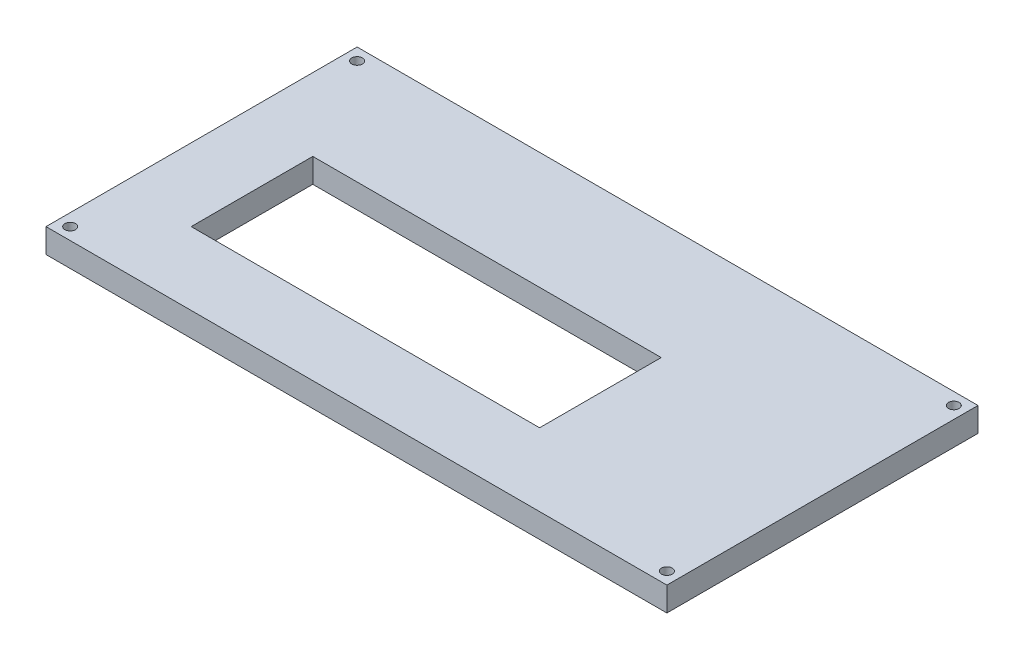
from build123d import *

# Parameters (mm, degrees)
SKETCH1_W           = 128.3
SKETCH1_H           = 64.29
BOSS_EXTRUDE1_DEPTH = 5
SKETCH2_R           = 1.1
CUT_EXTRUDE1_DEPTH  = 6
SKETCH3_W           = 72
SKETCH3_H           = 25.13
CUT_EXTRUDE2_DEPTH  = 6


with BuildPart() as part:
    # Sketch1 → Boss-Extrude1 (new body)
    with BuildSketch(Plane(origin=(0, 0, 0), x_dir=(1, 0, 0), z_dir=(0, 1, 0))):
        with Locations((-64.15, 32.145)):
            Rectangle(SKETCH1_W, SKETCH1_H)
    extrude(amount=BOSS_EXTRUDE1_DEPTH)

    # Sketch2 → Cut-Extrude1 (cut, through all)
    with BuildSketch(Plane(origin=(0, 0, 0), x_dir=(-1, 0, 0), z_dir=(0, -1, 0))):
        with Locations((125.8, 2.5)):
            Circle(SKETCH2_R)
        with Locations((125.8, 61.79)):
            Circle(SKETCH2_R)
        with Locations((2.5, 2.5)):
            Circle(SKETCH2_R)
        with Locations((2.5, 61.79)):
            Circle(SKETCH2_R)
    extrude(amount=-CUT_EXTRUDE1_DEPTH, mode=Mode.SUBTRACT)

    # Sketch3 → Cut-Extrude2 (cut, through all)
    with BuildSketch(Plane.XZ):
        with Locations((-77.3, -27.565)):
            Rectangle(SKETCH3_W, SKETCH3_H)
    extrude(amount=-CUT_EXTRUDE2_DEPTH, mode=Mode.SUBTRACT)


solid = part.part
